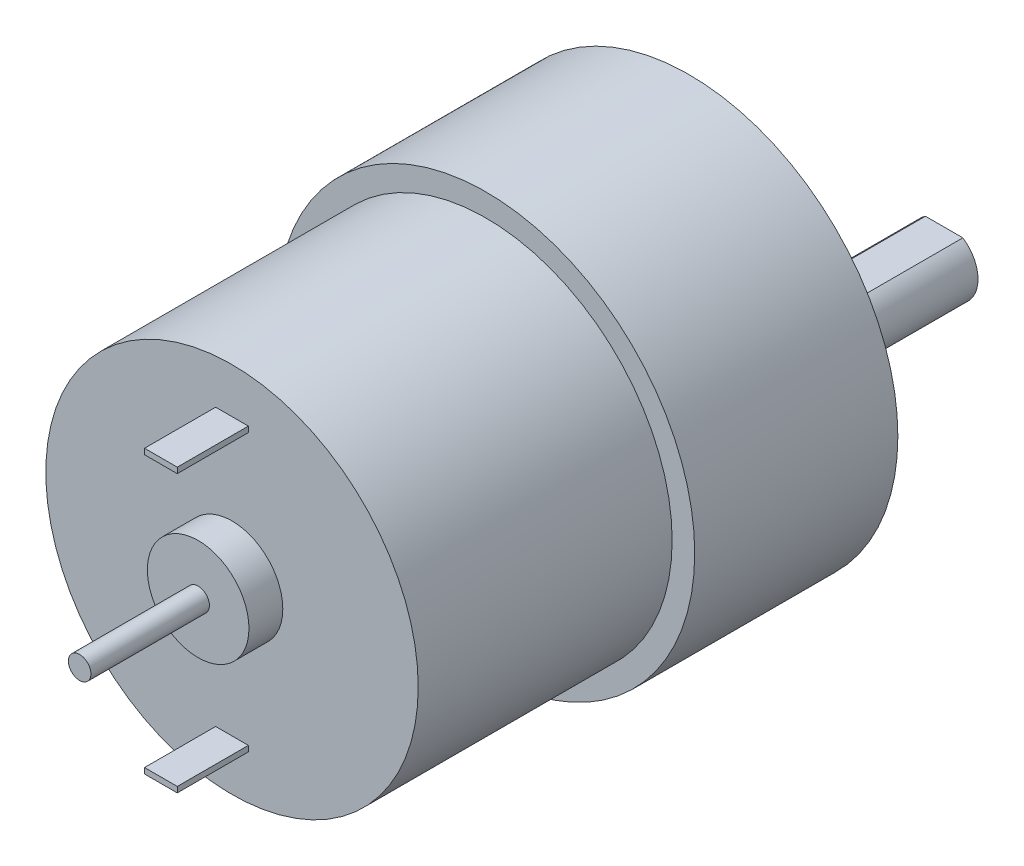
from build123d import *

# Parameters (mm, degrees)
CROQUIS1_R              = 18.5
SALIENTE_EXTRUIR1_DEPTH = 18
CROQUIS2_R              = 16.5
SALIENTE_EXTRUIR2_DEPTH = 22.5
CROQUIS3_R              = 4.5
SALIENTE_EXTRUIR3_DEPTH = 3
CROQUIS4_R              = 1
SALIENTE_EXTRUIR4_DEPTH = 10.5
CROQUIS5_W              = 2.9
CROQUIS5_H              = 0.5
SALIENTE_EXTRUIR5_DEPTH = 6.3
CROQUIS6_R              = 6
SALIENTE_EXTRUIR6_DEPTH = 4.6
CROQUIS7_R              = 3
SALIENTE_EXTRUIR7_DEPTH = 6
SALIENTE_EXTRUIR8_DEPTH = 12
CROQUIS9_R              = 1.5
CORTAR_EXTRUIR1_DEPTH   = 5


with BuildPart() as part:
    # Croquis1 → Saliente-Extruir1 (new body)
    with BuildSketch(Plane.XY):
        Circle(CROQUIS1_R)
    extrude(amount=SALIENTE_EXTRUIR1_DEPTH)

    # Croquis2 → Saliente-Extruir2 (add)
    with BuildSketch(Plane.XY.offset(18)):
        Circle(CROQUIS2_R)
    extrude(amount=SALIENTE_EXTRUIR2_DEPTH)

    # Croquis3 → Saliente-Extruir3 (add)
    with BuildSketch(Plane.XY.offset(40.5)):
        Circle(CROQUIS3_R)
    extrude(amount=SALIENTE_EXTRUIR3_DEPTH)

    # Croquis4 → Saliente-Extruir4 (add)
    with BuildSketch(Plane.XY.offset(43.5)):
        Circle(CROQUIS4_R)
    extrude(amount=SALIENTE_EXTRUIR4_DEPTH)

    # Croquis5 → Saliente-Extruir5 (add)
    with BuildSketch(Plane.XY.offset(40.5)):
        with Locations((0, 12.25)):
            Rectangle(CROQUIS5_W, CROQUIS5_H)
        with Locations((0, -12.25)):
            Rectangle(CROQUIS5_W, CROQUIS5_H)
    extrude(amount=SALIENTE_EXTRUIR5_DEPTH)

    # Croquis6 → Saliente-Extruir6 (add)
    with BuildSketch(Plane(origin=(0, 0, 0), x_dir=(-1, 0, 0), z_dir=(0, 0, -1))):
        with Locations((0, -7)):
            Circle(CROQUIS6_R)
    extrude(amount=SALIENTE_EXTRUIR6_DEPTH)

    # Croquis7 → Saliente-Extruir7 (add)
    with BuildSketch(Plane(origin=(0, 0, -4.6), x_dir=(-1, 0, 0), z_dir=(0, 0, -1))):
        with Locations((0, -7)):
            Circle(CROQUIS7_R)
    extrude(amount=SALIENTE_EXTRUIR7_DEPTH)

    # Croquis8 → Saliente-Extruir8 (add)
    with BuildSketch(Plane(origin=(0, 0, -10.6), x_dir=(-1, 0, 0), z_dir=(0, 0, -1))):
        with BuildLine():
            Line((-1.658312395, -4.5), (1.658312395, -4.5))
            ThreePointArc((1.658312395, -4.5), (0, -10), (-1.658312395, -4.5))
        make_face()
    extrude(amount=SALIENTE_EXTRUIR8_DEPTH)

    # Croquis9 → Cortar-Extruir1 (cut)
    with BuildSketch(Plane(origin=(0, 0, 0), x_dir=(-1, 0, 0), z_dir=(0, 0, -1))):
        with Locations((-7.75, 13.423393759)):
            Circle(CROQUIS9_R)
        with Locations((-15.5, 0)):
            Circle(CROQUIS9_R)
        with Locations((-7.75, -13.423393759)):
            Circle(CROQUIS9_R)
        with Locations((15.5, 0)):
            Circle(CROQUIS9_R)
    extrude(amount=-CORTAR_EXTRUIR1_DEPTH, mode=Mode.SUBTRACT)


solid = part.part
